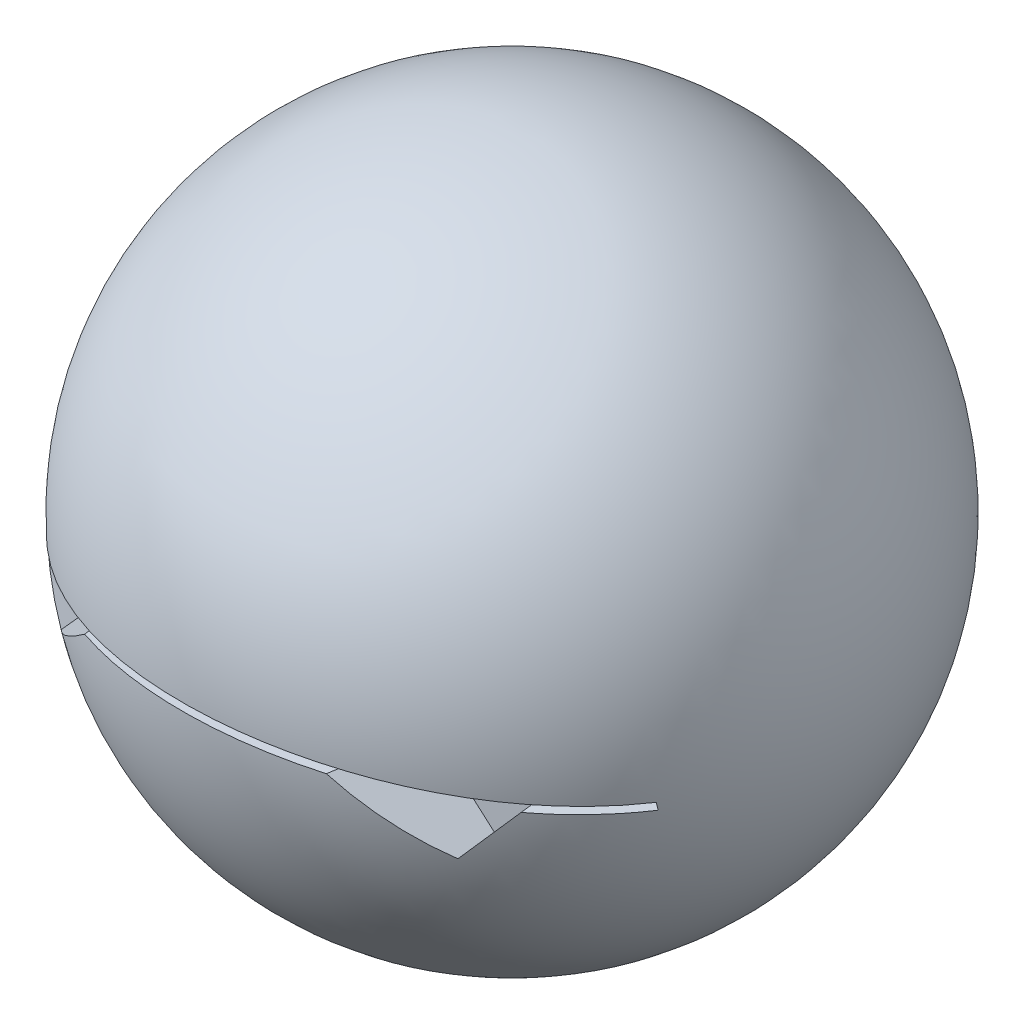
from build123d import *

# Parameters (mm, degrees)
ENL_V_MAT_EXTRU_2_DEPTH = 11.698916896
ENL_V_MAT_EXTRU_4_DEPTH = 3
ENL_V_MAT_EXTRU_4_TAPER = 5


with BuildPart() as part:
    # Esquisse1 → Révol.-Mince1 (revolve)
    with BuildSketch(Plane.XY):
        with BuildLine():
            ThreePointArc((0, 10.698916896), (10.698916896, 0), (0, -10.698916896))
            Line((0, -10.698916896), (0, -0.698916896))
            ThreePointArc((0, -0.698916896), (0.698916896, 0), (0, 0.698916896))
            Line((0, 0.698916896), (0, 10.698916896))
        make_face()
    revolve(axis=Axis((0, -3.545926921, 0), (0, 1, 0)))

    # Esquisse2 → Enlèv. mat.-Extru.2 (cut, through all)
    with BuildSketch(Plane.XY):
        with BuildLine():
            Line((-9.498856237, -1.25), (-9.5, -1))
            add(Edge.make_bspline(
                [(-9.5, -1), (0, 1), (9.5, -1)],
                knots=[0, 0, 0, 1, 1, 1], degree=2))
            Line((9.5, -1), (9.501143763, -1.25))
            add(Edge.make_bspline(
                [(-9.498856237, -1.25), (0.001143763, 0.750101861), (9.501143763, -1.25)],
                knots=[0, 0, 0, 1, 1, 1], degree=2))
        make_face()
    extrude(amount=ENL_V_MAT_EXTRU_2_DEPTH, mode=Mode.SUBTRACT)

    # Esquisse4 → Enlèv. mat.-Extru.4 (cut)
    with BuildSketch(Plane.XY.offset(10)):
        Polygon((3.719730148, -0.25), (6.452328662, -2.65272264), (8.21328513, -0.65), align=None)
        Polygon((-6.452328662, -2.65272264), (-3.719730148, -0.25), (-8.21328513, -0.65), align=None)
    extrude(amount=-ENL_V_MAT_EXTRU_4_DEPTH, taper=ENL_V_MAT_EXTRU_4_TAPER, mode=Mode.SUBTRACT)


solid = part.part
